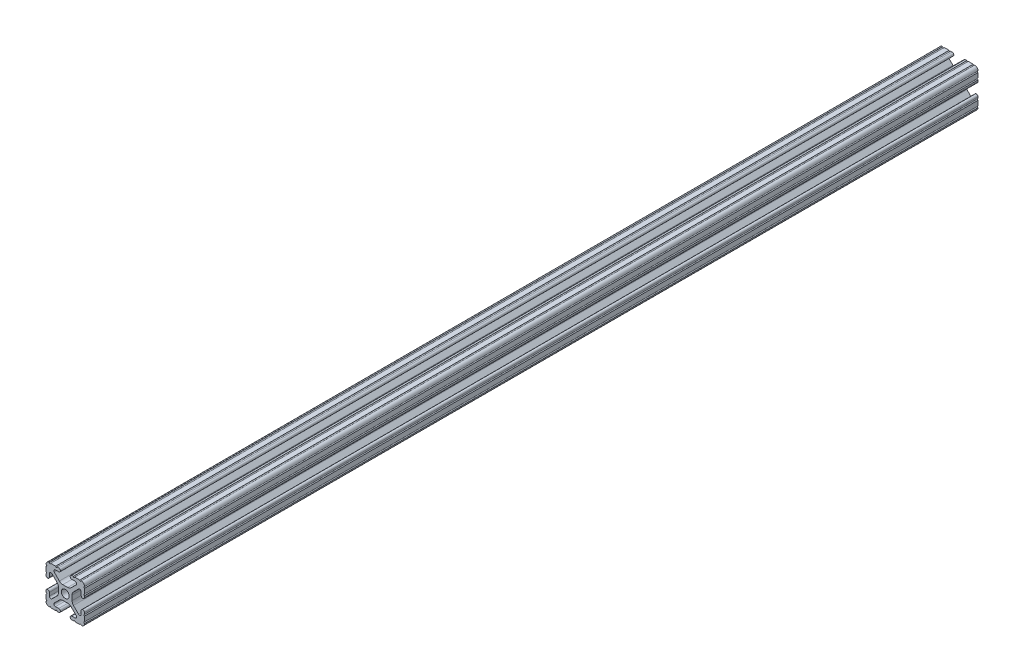
from build123d import *

# Parameters (mm, degrees)
SKETCH1_R           = 2.6035
BOSS_EXTRUDE1_DEPTH = 589.153


with BuildPart() as part:
    # Sketch1 → Boss-Extrude1 (new body)
    with BuildSketch(Plane(origin=(0, 0, -450.85), x_dir=(-1, 0, 0), z_dir=(0, 0, -1))):
        with BuildLine():
            Line((12.7, -9.5504), (12.7, -6.3330836))
            ThreePointArc((12.7, -6.3330836), (12.192, -5.8250836), (12.7, -5.3170836))
            Line((12.7, -5.3170836), (12.7, -4.3434))
            ThreePointArc((12.7, -4.3434), (11.5951, -3.2385), (10.4902, -4.3434))
            Line((10.4902, -4.3434), (10.4902, -6.474794456))
            ThreePointArc((10.4902, -6.474794456), (9.863006367, -7.413456061), (8.75577951, -7.193214945))
            Line((8.75577951, -7.193214945), (5.42573597, -3.863171405))
            ThreePointArc((5.42573597, -3.863171405), (4.737482484, -2.833127272), (4.4958, -1.618107374))
            Line((4.4958, -1.618107374), (4.4958, 1.618107374))
            ThreePointArc((4.4958, 1.618107374), (4.737482484, 2.833127272), (5.42573597, 3.863171405))
            Line((5.42573597, 3.863171405), (8.75577951, 7.193214945))
            ThreePointArc((8.75577951, 7.193214945), (9.863006367, 7.413456061), (10.4902, 6.474794456))
            Line((10.4902, 6.474794456), (10.4902, 4.343399971))
            ThreePointArc((10.4902, 4.343399971), (11.5951, 3.238499971), (12.7, 4.343399971))
            Line((12.7, 4.343399971), (12.7, 5.3170836))
            ThreePointArc((12.7, 5.3170836), (12.192, 5.8250836), (12.7, 6.3330836))
            Line((12.7, 6.3330836), (12.7, 9.5504))
            ThreePointArc((12.7, 9.5504), (12.192000006, 10.058323491), (12.699846982, 10.566399977))
            ThreePointArc((12.699846982, 10.566399977), (12.082522516, 12.082522516), (10.566399977, 12.699846982))
            ThreePointArc((10.566399977, 12.699846982), (10.058323491, 12.192000006), (9.5504, 12.7))
            Line((9.5504, 12.7), (6.3330836, 12.7))
            ThreePointArc((6.3330836, 12.7), (5.8250836, 12.192), (5.3170836, 12.7))
            Line((5.3170836, 12.7), (4.3434, 12.7))
            ThreePointArc((4.3434, 12.7), (3.2385, 11.5951), (4.3434, 10.4902))
            Line((4.3434, 10.4902), (6.474794456, 10.4902))
            ThreePointArc((6.474794456, 10.4902), (7.413456061, 9.863006367), (7.193214945, 8.75577951))
            Line((7.193214945, 8.75577951), (3.863171405, 5.42573597))
            ThreePointArc((3.863171405, 5.42573597), (2.833127272, 4.737482484), (1.618107374, 4.4958))
            Line((1.618107374, 4.4958), (-1.618107374, 4.4958))
            ThreePointArc((-1.618107374, 4.4958), (-2.833127272, 4.737482484), (-3.863171405, 5.42573597))
            Line((-3.863171405, 5.42573597), (-7.193214945, 8.75577951))
            ThreePointArc((-7.193214945, 8.75577951), (-7.413456061, 9.863006367), (-6.474794456, 10.4902))
            Line((-6.474794456, 10.4902), (-4.343399971, 10.4902))
            ThreePointArc((-4.343399971, 10.4902), (-3.238499971, 11.5951), (-4.343399971, 12.7))
            Line((-4.343399971, 12.7), (-5.3170836, 12.7))
            ThreePointArc((-5.3170836, 12.7), (-5.8250836, 12.192), (-6.3330836, 12.7))
            Line((-6.3330836, 12.7), (-9.5504, 12.7))
            ThreePointArc((-9.5504, 12.7), (-10.058323491, 12.192000006), (-10.566399977, 12.699846982))
            ThreePointArc((-10.566399977, 12.699846982), (-12.082522516, 12.082522516), (-12.699846982, 10.566399977))
            ThreePointArc((-12.699846982, 10.566399977), (-12.192000006, 10.058323491), (-12.7, 9.5504))
            Line((-12.7, 9.5504), (-12.7, 6.3330836))
            ThreePointArc((-12.7, 6.3330836), (-12.192, 5.8250836), (-12.7, 5.3170836))
            Line((-12.7, 5.3170836), (-12.7, 4.3434))
            ThreePointArc((-12.7, 4.3434), (-11.5951, 3.2385), (-10.4902, 4.3434))
            Line((-10.4902, 4.3434), (-10.4902, 6.474794456))
            ThreePointArc((-10.4902, 6.474794456), (-9.863006367, 7.413456061), (-8.75577951, 7.193214945))
            Line((-8.75577951, 7.193214945), (-5.42573597, 3.863171405))
            ThreePointArc((-5.42573597, 3.863171405), (-4.737482484, 2.833127272), (-4.4958, 1.618107374))
            Line((-4.4958, 1.618107374), (-4.4958, -1.618107374))
            ThreePointArc((-4.4958, -1.618107374), (-4.737482484, -2.833127272), (-5.42573597, -3.863171405))
            Line((-5.42573597, -3.863171405), (-8.75577951, -7.193214945))
            ThreePointArc((-8.75577951, -7.193214945), (-9.863006367, -7.413456061), (-10.4902, -6.474794456))
            Line((-10.4902, -6.474794456), (-10.4902, -4.343399971))
            ThreePointArc((-10.4902, -4.343399971), (-11.5951, -3.238499971), (-12.7, -4.343399971))
            Line((-12.7, -4.343399971), (-12.7, -5.3170836))
            ThreePointArc((-12.7, -5.3170836), (-12.192, -5.8250836), (-12.7, -6.3330836))
            Line((-12.7, -6.3330836), (-12.7, -9.5504))
            ThreePointArc((-12.7, -9.5504), (-12.192000006, -10.058323491), (-12.699846982, -10.566399977))
            ThreePointArc((-12.699846982, -10.566399977), (-12.082522516, -12.082522516), (-10.566399977, -12.699846982))
            ThreePointArc((-10.566399977, -12.699846982), (-10.058323491, -12.192000006), (-9.5504, -12.7))
            Line((-9.5504, -12.7), (-6.3330836, -12.7))
            ThreePointArc((-6.3330836, -12.7), (-5.8250836, -12.192), (-5.3170836, -12.7))
            Line((-5.3170836, -12.7), (-4.3434, -12.7))
            ThreePointArc((-4.3434, -12.7), (-3.2385, -11.5951), (-4.3434, -10.4902))
            Line((-4.3434, -10.4902), (-6.474794456, -10.4902))
            ThreePointArc((-6.474794456, -10.4902), (-7.413456061, -9.863006367), (-7.193214945, -8.75577951))
            Line((-7.193214945, -8.75577951), (-3.863171405, -5.42573597))
            ThreePointArc((-3.863171405, -5.42573597), (-2.833127272, -4.737482484), (-1.618107374, -4.4958))
            Line((-1.618107374, -4.4958), (1.618107374, -4.4958))
            ThreePointArc((1.618107374, -4.4958), (2.833127272, -4.737482484), (3.863171405, -5.42573597))
            Line((3.863171405, -5.42573597), (7.193214945, -8.75577951))
            ThreePointArc((7.193214945, -8.75577951), (7.413456061, -9.863006367), (6.474794456, -10.4902))
            Line((6.474794456, -10.4902), (4.343399971, -10.4902))
            ThreePointArc((4.343399971, -10.4902), (3.238499971, -11.5951), (4.343399971, -12.7))
            Line((4.343399971, -12.7), (5.3170836, -12.7))
            ThreePointArc((5.3170836, -12.7), (5.8250836, -12.192), (6.3330836, -12.7))
            Line((6.3330836, -12.7), (9.5504, -12.7))
            ThreePointArc((9.5504, -12.7), (10.058323491, -12.192000006), (10.566399977, -12.699846982))
            ThreePointArc((10.566399977, -12.699846982), (12.082522516, -12.082522516), (12.699846982, -10.566399977))
            ThreePointArc((12.699846982, -10.566399977), (12.192000006, -10.058323491), (12.7, -9.5504))
        make_face()
        Circle(SKETCH1_R, mode=Mode.SUBTRACT)
    extrude(amount=-BOSS_EXTRUDE1_DEPTH)


solid = part.part
